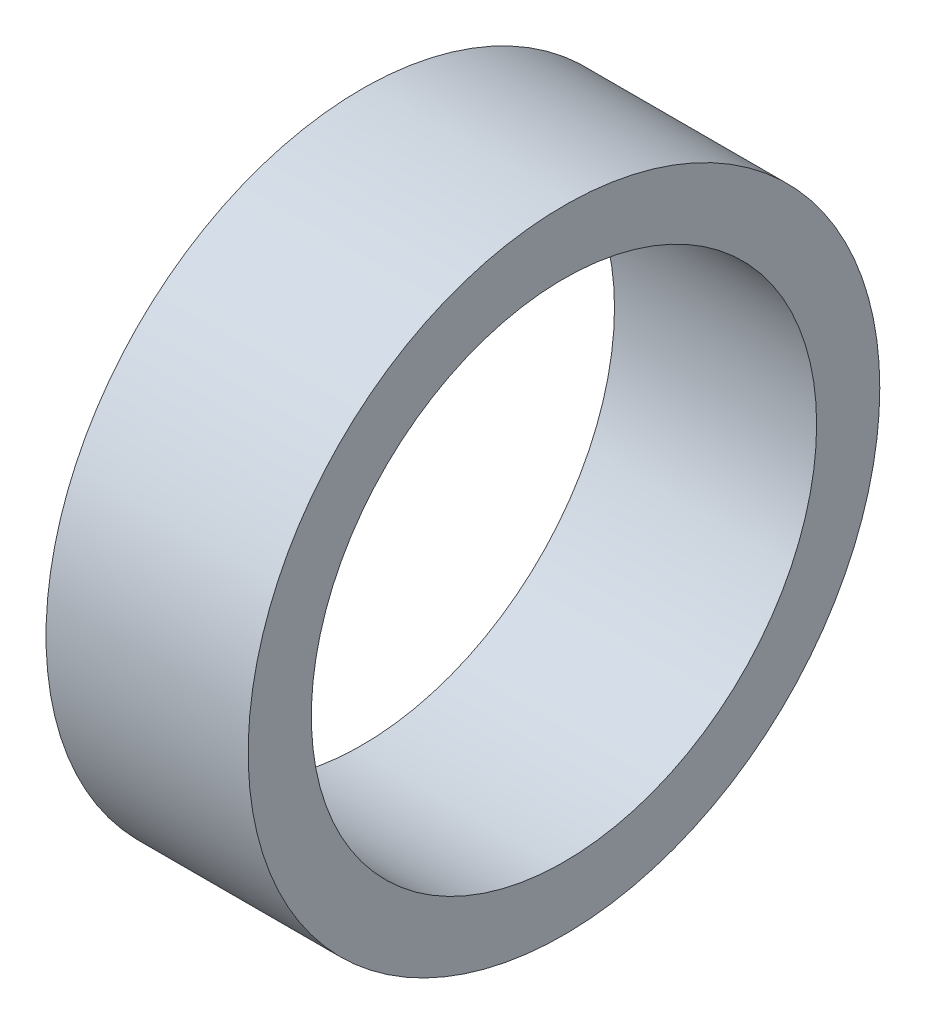
from build123d import *

# Parameters (mm, degrees)
SKETCH1_R           = 12.5
SKETCH1_R_2         = 10
BOSS_EXTRUDE1_DEPTH = 8


with BuildPart() as part:
    # Sketch1 → Boss-Extrude1 (new body)
    with BuildSketch(Plane(origin=(0, 0, 0), x_dir=(0, 0, -1), z_dir=(1, 0, 0))):
        Circle(SKETCH1_R)
        Circle(SKETCH1_R_2, mode=Mode.SUBTRACT)
    extrude(amount=BOSS_EXTRUDE1_DEPTH)


solid = part.part
